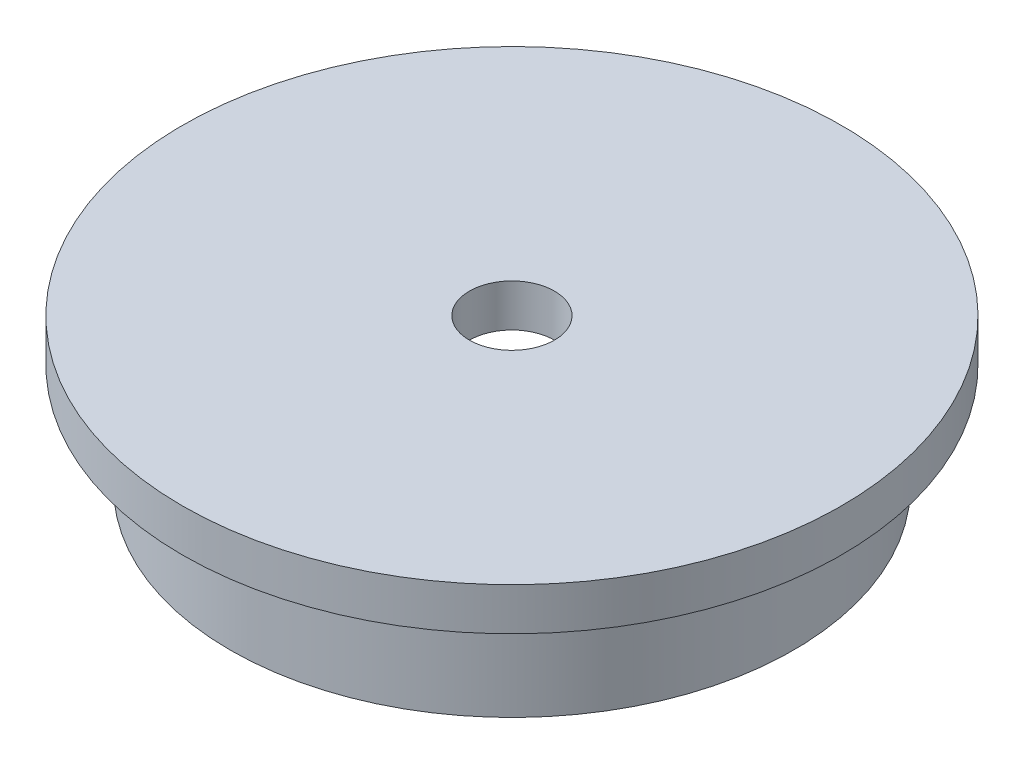
from build123d import *

# Parameters (mm, degrees)
SKETCH1_R               = 33.655
SKETCH1_R_2             = 28.575
BOSS_EXTRUDE1_DEPTH     = 12.7
SKETCH2_R               = 39.37
BOSS_EXTRUDE2_DEPTH     = 5.08
SKETCH3_R               = 5.08
CUT_EXTRUDE1_DEPTH      = 1
CUT_EXTRUDE1_DEPTH_BACK = 18.78


with BuildPart() as part:
    # Sketch1 → Boss-Extrude1 (new body)
    with BuildSketch(Plane(origin=(0, 0, 0), x_dir=(1, 0, 0), z_dir=(0, 1, 0))):
        Circle(SKETCH1_R)
        Circle(SKETCH1_R_2, mode=Mode.SUBTRACT)
    extrude(amount=BOSS_EXTRUDE1_DEPTH)

    # Sketch2 → Boss-Extrude2 (add)
    with BuildSketch(Plane(origin=(0, 12.7, 0), x_dir=(1, 0, 0), z_dir=(0, 1, 0))):
        Circle(SKETCH2_R)
    extrude(amount=BOSS_EXTRUDE2_DEPTH)

    # Sketch3 → Cut-Extrude1 (cut, two sides)
    with BuildSketch(Plane(origin=(0, 17.78, 0), x_dir=(1, 0, 0), z_dir=(0, 1, 0))) as cut_extrude1_sk:
        Circle(SKETCH3_R)
    extrude(amount=CUT_EXTRUDE1_DEPTH, mode=Mode.SUBTRACT)
    extrude(cut_extrude1_sk.sketch, amount=-CUT_EXTRUDE1_DEPTH_BACK, mode=Mode.SUBTRACT)


solid = part.part
